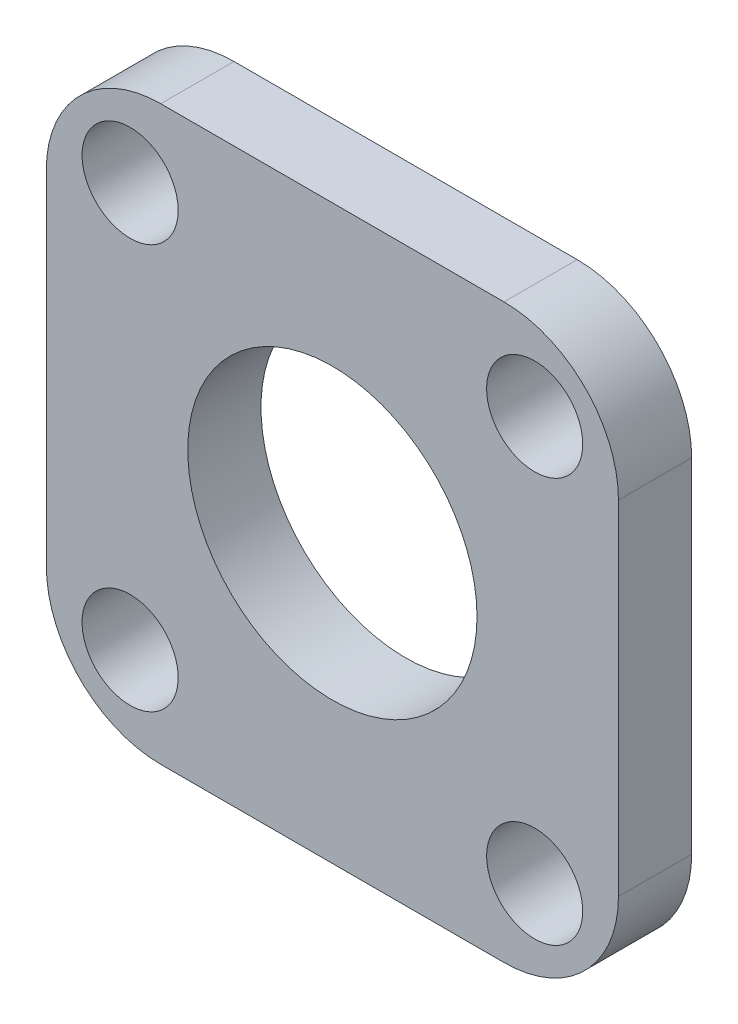
from build123d import *

# Parameters (mm, degrees)
SKETCH1_W           = 25
SKETCH1_H           = 25
BOSS_EXTRUDE1_DEPTH = 3.2
CUT_EXTRUDE1_REACH  = 5.2
SKETCH2_R           = 6.32
SKETCH3_R           = 2.1
CUT_EXTRUDE2_DEPTH  = 4.2
CIRPATTERN1_COUNT   = 4
FILLET2_R           = 5


with BuildPart() as part:
    # Sketch1 → Boss-Extrude1 (new body)
    with BuildSketch(Plane.XY):
        Rectangle(SKETCH1_W, SKETCH1_H)
    extrude(amount=BOSS_EXTRUDE1_DEPTH)

    # Sketch2 → Cut-Extrude1 (cut, up to next)
    with BuildSketch(Plane.XY.offset(3.2), mode=Mode.PRIVATE) as cut_extrude1_sk1:
        Circle(SKETCH2_R)
    cut_extrude1_tool1 = extrude(cut_extrude1_sk1.sketch, amount=-CUT_EXTRUDE1_REACH, mode=Mode.PRIVATE) & part.part
    add(cut_extrude1_tool1.solids().sort_by_distance((0, 0, 3.2))[0], mode=Mode.SUBTRACT)

    # Sketch3 → Cut-Extrude2 (cut, through all)
    with BuildSketch(Plane.XY.offset(3.2)):
        with Locations((-8.838834765, 8.838834765)):
            Circle(SKETCH3_R)
    cut_extrude2 = extrude(amount=-CUT_EXTRUDE2_DEPTH, mode=Mode.SUBTRACT)

    # CirPattern1: Cut-Extrude2 ×4 about axis
    cirpattern1_axis = Axis((0, 0, 0), (0, 0, 1))
    for i in range(1, CIRPATTERN1_COUNT):
        add(cut_extrude2.rotate(cirpattern1_axis, i * 360 / CIRPATTERN1_COUNT), mode=Mode.SUBTRACT)

    # Fillet2
    fillet2_edges = [part.edges().sort_by_distance(p)[0] for p in [
        (12.5, -12.5, 1.6),
        (-12.5, -12.5, 1.6),
        (-12.5, 12.5, 1.6),
        (12.5, 12.5, 1.6),
    ]]
    fillet(fillet2_edges, radius=FILLET2_R)


solid = part.part
